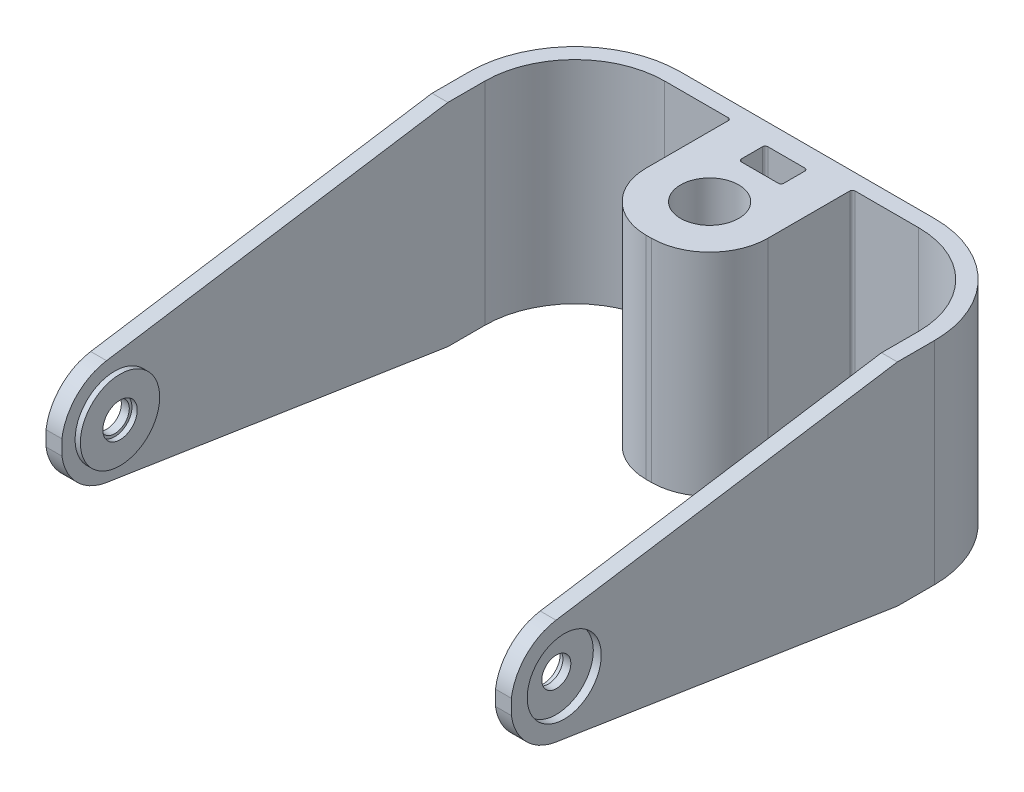
from build123d import *

# Parameters (mm, degrees)
SKETCH1_W           = 88
SKETCH1_H           = 40
BOSS_EXTRUDE1_DEPTH = 100
SKETCH2_R           = 5.5
CUT_EXTRUDE1_DEPTH  = 40
CUT_EXTRUDE2_START  = -13.73686
SKETCH3_R           = 2.75
CUT_EXTRUDE2_DEPTH  = 13.73686
SKETCH5_R           = 2.75
CUT_EXTRUDE3_DEPTH  = 3
SKETCH6_R           = 2.75
CUT_EXTRUDE4_DEPTH  = 3
SKETCH7_R           = 7.5
SKETCH7_R_2         = 3.25
BOSS_EXTRUDE2_DEPTH = 1
SKETCH8_R           = 7.5
SKETCH8_R_2         = 3.25
BOSS_EXTRUDE3_DEPTH = 1
SKETCH9_R           = 7
CUT_EXTRUDE5_DEPTH  = 1.5
SKETCH10_R          = 7
CUT_EXTRUDE6_DEPTH  = 1.5


with BuildPart() as part:
    # Sketch1 → Boss-Extrude1 (new body)
    with BuildSketch(Plane.XY):
        with Locations((44, 20)):
            Rectangle(SKETCH1_W, SKETCH1_H)
    extrude(amount=BOSS_EXTRUDE1_DEPTH)

    # Sketch2 → Cut-Extrude1 (cut)
    with BuildSketch(Plane.XZ):
        with Locations((44, 18.5)):
            Circle(SKETCH2_R)
        with BuildLine():
            Line((20, 3), (32, 3))
            ThreePointArc((32, 3), (32.353553391, 3.146446609), (32.5, 3.5))
            Line((32.5, 3.5), (32.5, 19))
            ThreePointArc((32.5, 19), (35.721825407, 26.778174593), (43.5, 30))
            Line((43.5, 30), (44.5, 30))
            ThreePointArc((44.5, 30), (52.278174593, 26.778174593), (55.5, 19))
            Line((55.5, 19), (55.5, 3.5))
            ThreePointArc((55.5, 3.5), (55.646446609, 3.146446609), (56, 3))
            Line((56, 3), (68, 3))
            ThreePointArc((68, 3), (80.02081528, 7.97918472), (85, 20))
            Line((85, 20), (85, 100))
            Line((85, 100), (3, 100))
            Line((3, 100), (3, 20))
            ThreePointArc((3, 20), (7.97918472, 7.97918472), (20, 3))
        make_face()
        with BuildLine():
            Line((0, 20), (0, 0))
            Line((0, 0), (20, 0))
            ThreePointArc((20, 0), (5.857864376, 5.857864376), (0, 20))
        make_face()
        with BuildLine():
            Line((68, 0), (88, 0))
            Line((88, 0), (88, 20))
            ThreePointArc((88, 20), (82.142135624, 5.857864376), (68, 0))
        make_face()
        with BuildLine():
            Line((40.5, 9), (47.5, 9))
            ThreePointArc((47.5, 9), (47.853553391, 8.853553391), (48, 8.5))
            Line((48, 8.5), (48, 4.5))
            ThreePointArc((48, 4.5), (47.853553391, 4.146446609), (47.5, 4))
            Line((47.5, 4), (40.5, 4))
            ThreePointArc((40.5, 4), (40.146446609, 4.146446609), (40, 4.5))
            Line((40, 4.5), (40, 8.5))
            ThreePointArc((40, 8.5), (40.146446609, 8.853553391), (40.5, 9))
        make_face()
    extrude(amount=-CUT_EXTRUDE1_DEPTH, mode=Mode.SUBTRACT)

    # Sketch3 → Cut-Extrude2 (cut)
    with BuildSketch(Plane(origin=(0, 0, 0), x_dir=(-1, 0, 0), z_dir=(0, 0, -1)).offset(CUT_EXTRUDE2_START)):
        with Locations((-44, 20)):
            Circle(SKETCH3_R)
    extrude(amount=CUT_EXTRUDE2_DEPTH, mode=Mode.SUBTRACT)

    # Sketch5 → Cut-Extrude3 (cut)
    with BuildSketch(Plane(origin=(88, 0, 0), x_dir=(0, 0, -1), z_dir=(1, 0, 0))):
        with Locations((-90, 20)):
            Circle(SKETCH5_R)
        with BuildLine():
            Line((-27, 0), (-100, 0))
            Line((-100, 0), (-100, 18.582255312))
            ThreePointArc((-100, 18.582255312), (-97.188609996, 12.905362143), (-91.549199975, 10.01952008))
            Line((-91.549199975, 10.01952008), (-27, 0))
        make_face()
        with BuildLine():
            Line((-100, 40), (-27, 40))
            Line((-27, 40), (-91.549199975, 29.98047992))
            ThreePointArc((-91.549199975, 29.98047992), (-97.188609996, 27.094637857), (-100, 21.417744688))
            Line((-100, 21.417744688), (-100, 40))
        make_face()
    extrude(amount=-CUT_EXTRUDE3_DEPTH, mode=Mode.SUBTRACT)

    # Sketch6 → Cut-Extrude4 (cut)
    with BuildSketch(Plane.ZY):
        with Locations((90, 20)):
            Circle(SKETCH6_R)
        with BuildLine():
            Line((100, 0), (100, 18.582255312))
            ThreePointArc((100, 18.582255312), (97.188609996, 12.905362143), (91.549199975, 10.01952008))
            Line((91.549199975, 10.01952008), (27, 0))
            Line((27, 0), (100, 0))
        make_face()
        with BuildLine():
            Line((100, 21.417744688), (100, 40))
            Line((100, 40), (27, 40))
            Line((27, 40), (91.549199975, 29.98047992))
            ThreePointArc((91.549199975, 29.98047992), (97.188609996, 27.094637857), (100, 21.417744688))
        make_face()
    extrude(amount=-CUT_EXTRUDE4_DEPTH, mode=Mode.SUBTRACT)

    # Sketch7 → Boss-Extrude2 (add)
    with BuildSketch(Plane(origin=(3, 0, 0), x_dir=(0, 0, -1), z_dir=(1, 0, 0))):
        with Locations((-90, 20)):
            Circle(SKETCH7_R)
        with Locations((-90, 20)):
            Circle(SKETCH7_R_2, mode=Mode.SUBTRACT)
    extrude(amount=BOSS_EXTRUDE2_DEPTH)

    # Sketch8 → Boss-Extrude3 (add)
    with BuildSketch(Plane.ZY.offset(-85)):
        with Locations((90, 20)):
            Circle(SKETCH8_R)
        with Locations((90, 20)):
            Circle(SKETCH8_R_2, mode=Mode.SUBTRACT)
    extrude(amount=BOSS_EXTRUDE3_DEPTH)

    # Sketch9 → Cut-Extrude5 (cut)
    with BuildSketch(Plane(origin=(88, 0, 0), x_dir=(0, 0, -1), z_dir=(1, 0, 0))):
        with Locations((-90, 20)):
            Circle(SKETCH9_R)
    extrude(amount=-CUT_EXTRUDE5_DEPTH, mode=Mode.SUBTRACT)

    # Sketch10 → Cut-Extrude6 (cut)
    with BuildSketch(Plane.ZY):
        with Locations((90, 20)):
            Circle(SKETCH10_R)
    extrude(amount=-CUT_EXTRUDE6_DEPTH, mode=Mode.SUBTRACT)


solid = part.part
